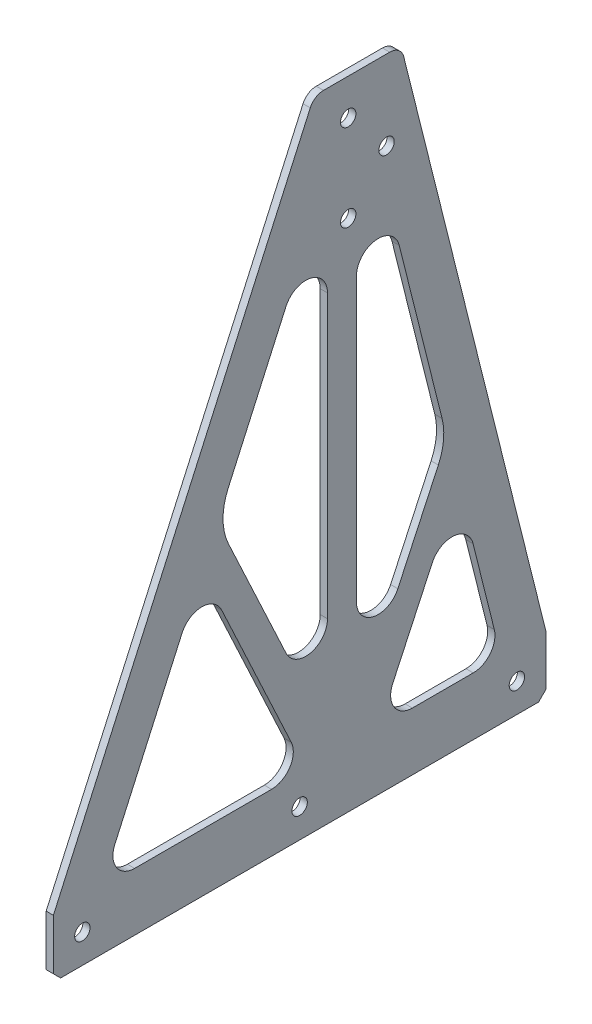
from build123d import *

# Parameters (mm, degrees)
BOSS_EXTRUDE1_DEPTH = 3.175
SKETCH3_R           = 3.3782
CUT_EXTRUDE2_DEPTH  = 4.175
SKETCH4_R           = 3.3782
CUT_EXTRUDE3_DEPTH  = 4.175
CHAMFER1_SIZE       = 3.175
CUT_EXTRUDE4_DEPTH  = 4.175


with BuildPart() as part:
    # Sketch1 → Boss-Extrude1 (new body)
    with BuildSketch(Plane(origin=(0, 0, 0), x_dir=(0, 0, -1), z_dir=(1, 0, 0))):
        with BuildLine():
            Line((118.405818623, 279.4), (147.442069819, 279.4))
            ThreePointArc((147.442069819, 279.4), (151.349937349, 278.055104531), (153.602474695, 274.590101219))
            Line((153.602474695, 274.590101219), (215.9, 25.4))
            Line((215.9, 25.4), (215.9, 0))
            Line((215.9, 0), (0, 0))
            Line((0, 0), (0, 25.4))
            Line((0, 25.4), (112.615117065, 275.655815701))
            ThreePointArc((112.615117065, 275.655815701), (114.95795187, 278.382421106), (118.405818623, 279.4))
        make_face()
    extrude(amount=BOSS_EXTRUDE1_DEPTH)

    # Sketch3 → Cut-Extrude2 (cut, through all)
    with BuildSketch(Plane(origin=(3.175, 0, 0), x_dir=(0, 0, -1), z_dir=(1, 0, 0))):
        with Locations((146.05, 244.475)):
            Circle(SKETCH3_R)
        with Locations((129.249479175, 225.425)):
            Circle(SKETCH3_R)
        with Locations((129.249479175, 263.525)):
            Circle(SKETCH3_R)
    extrude(amount=-CUT_EXTRUDE2_DEPTH, mode=Mode.SUBTRACT)

    # Sketch4 → Cut-Extrude3 (cut, through all)
    with BuildSketch(Plane(origin=(3.175, 0, 0), x_dir=(0, 0, -1), z_dir=(1, 0, 0))):
        with Locations((12.7, 12.7)):
            Circle(SKETCH4_R)
        with Locations((107.95, 12.7)):
            Circle(SKETCH4_R)
        with Locations((203.2, 12.7)):
            Circle(SKETCH4_R)
    extrude(amount=-CUT_EXTRUDE3_DEPTH, mode=Mode.SUBTRACT)

    # Chamfer1
    chamfer1_edges = [part.edges().sort_by_distance(p)[0] for p in [
        (1.5875, 0, -215.9),
        (1.5875, 0, 0),
    ]]
    chamfer(chamfer1_edges, length=CHAMFER1_SIZE)

    # Sketch5 → Cut-Extrude4 (cut, through all)
    with BuildSketch(Plane(origin=(3.175, 0, 0), x_dir=(0, 0, -1), z_dir=(1, 0, 0))):
        with BuildLine():
            Line((35.621183805, 25.4), (95.655352116, 25.4))
            ThreePointArc((95.655352116, 25.4), (103.688655638, 29.80722123), (104.287933788, 38.950438943))
            Line((104.287933788, 38.950438943), (73.736631302, 104.467918555))
            ThreePointArc((73.736631302, 104.467918555), (65.039859299, 109.967263315), (56.417997293, 104.351203163))
            Line((56.417997293, 104.351203163), (26.935131468, 38.833723552))
            ThreePointArc((26.935131468, 38.833723552), (27.622552146, 29.75319987), (35.621183805, 25.4))
        make_face()
        with BuildLine():
            Line((101.952143857, 205.538195526), (76.606881892, 149.21539116))
            ThreePointArc((76.606881892, 149.21539116), (74.370264914, 138.620954139), (76.749470333, 128.057624508))
            Line((76.749470333, 128.057624508), (102.005614522, 73.895648509))
            ThreePointArc((102.005614522, 73.895648509), (112.699783516, 68.621867985), (120.163196193, 77.921087453))
            Line((120.163196193, 77.921087453), (120.163196193, 201.629471974))
            ThreePointArc((120.163196193, 201.629471974), (112.637067937, 210.942373603), (101.952143857, 205.538195526))
        make_face()
        with BuildLine():
            Line((151.628803507, 203.939623803), (170.39715385, 128.866222433))
            ThreePointArc((170.39715385, 128.866222433), (171.039366508, 120.279332191), (168.775752137, 111.971313709))
            Line((168.775752137, 111.971313709), (151.020777865, 73.895648509))
            ThreePointArc((151.020777865, 73.895648509), (140.326608871, 68.621867985), (132.863196193, 77.921087453))
            Line((132.863196193, 77.921087453), (132.863196193, 201.629471974))
            ThreePointArc((132.863196193, 201.629471974), (141.224400607, 211.083106452), (151.628803507, 203.939623803))
        make_face()
        with BuildLine():
            Line((157.371040271, 25.4), (184.064314187, 25.4))
            ThreePointArc((184.064314187, 25.4), (191.571970984, 29.063198705), (193.304921501, 37.235151828))
            Line((193.304921501, 37.235151828), (183.988647407, 74.500248205))
            ThreePointArc((183.988647407, 74.500248205), (175.657972105, 81.671533437), (166.115458421, 76.21553532))
            Line((166.115458421, 76.21553532), (148.738458599, 38.950438943))
            ThreePointArc((148.738458599, 38.950438943), (149.337736749, 29.80722123), (157.371040271, 25.4))
        make_face()
    extrude(amount=-CUT_EXTRUDE4_DEPTH, mode=Mode.SUBTRACT)


solid = part.part
